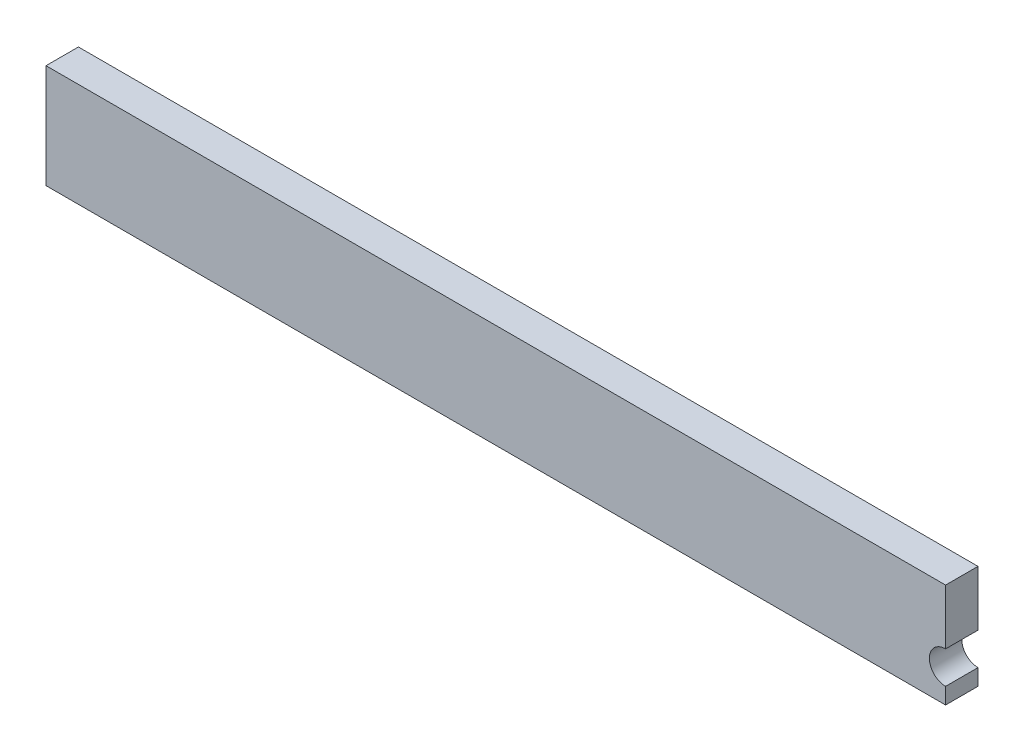
from build123d import *

# Parameters (mm, degrees)
EXTRUDE_1_DEPTH = 2


with BuildPart() as part:
    # Эскиз1 → Бобышка-Вытянуть1 (new body)
    with BuildSketch(Plane.XY):
        with BuildLine():
            Line((0, 6.41), (0, 0))
            Line((0, 0), (55.5, 0))
            Line((55.5, 0), (55.5, 1))
            ThreePointArc((55.5, 1), (54.5, 2), (55.5, 3))
            Line((55.5, 3), (55.5, 6.41))
            Line((55.5, 6.41), (0, 6.41))
        make_face()
    extrude(amount=EXTRUDE_1_DEPTH)


solid = part.part
